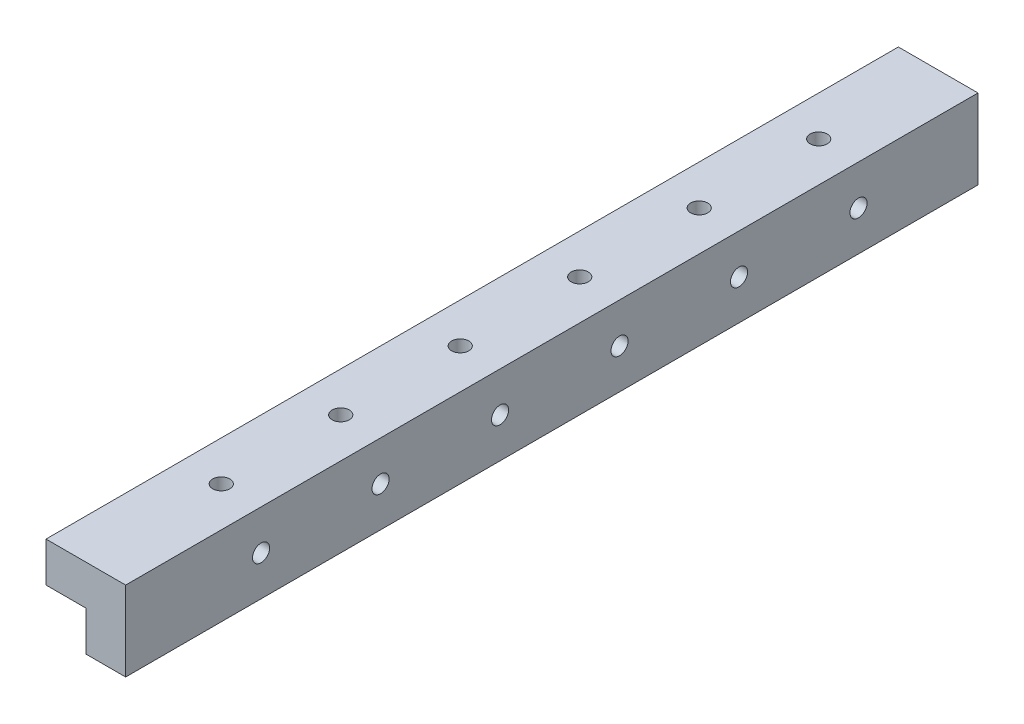
from build123d import *

# Parameters (mm, degrees)
BOSS_EXTRUDE1_DEPTH             = 214
TAP_DRILL_FOR_M3X0_5_TAP1_D     = 4.3
TAP_DRILL_FOR_M3X0_5_TAP1_DEPTH = 6.825
TAP_DRILL_FOR_M3X0_5_TAP2_D     = 4.3
TAP_DRILL_FOR_M3X0_5_TAP2_DEPTH = 6.825


with BuildPart() as part:
    # Sketch1 → Boss-Extrude1 (new body)
    with BuildSketch(Plane.XY):
        Polygon((0, -10), (10, -10), (10, 10), (-10, 10), (-10, 0), (0, 0), align=None)
    extrude(amount=-BOSS_EXTRUDE1_DEPTH)

    # Tap Drill for M3x0.5 Tap1
    with Locations(Plane(origin=(10, 0, 0), x_dir=(0, 0, -1), z_dir=(1, 0, 0))):
        with Locations((34, 0), (64, 0), (94, 0), (124, 0), (154, 0), (184, 0)):
            Hole(TAP_DRILL_FOR_M3X0_5_TAP1_D / 2, depth=TAP_DRILL_FOR_M3X0_5_TAP1_DEPTH)

    # Tap Drill for M3x0.5 Tap2
    with Locations(Plane(origin=(0, 10, 0), x_dir=(1, 0, 0), z_dir=(0, 1, 0))):
        with Locations((0, 34), (0, 64), (0, 94), (0, 124), (0, 154), (0, 184)):
            Hole(TAP_DRILL_FOR_M3X0_5_TAP2_D / 2, depth=TAP_DRILL_FOR_M3X0_5_TAP2_DEPTH)


solid = part.part
